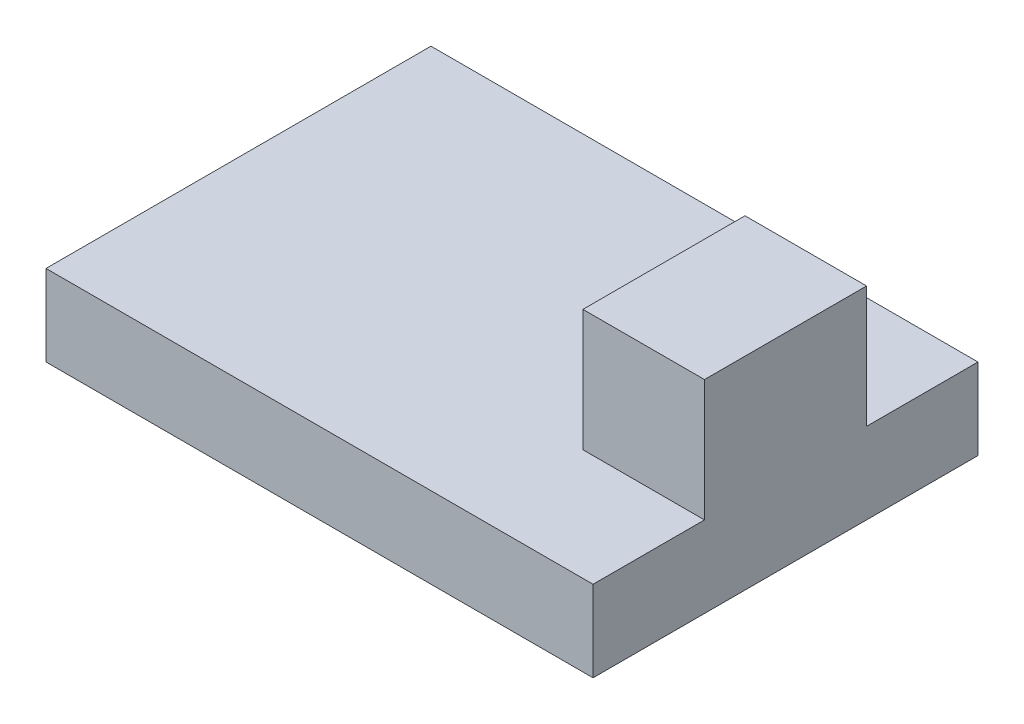
from build123d import *

# Parameters (mm, degrees)
SKETCH1_W           = 27
SKETCH1_H           = 19
BOSS_EXTRUDE1_DEPTH = 4
SKETCH2_W           = 6
SKETCH2_H           = 8
BOSS_EXTRUDE2_DEPTH = 6


with BuildPart() as part:
    # Sketch1 → Boss-Extrude1 (new body)
    with BuildSketch(Plane(origin=(0, 0, 0), x_dir=(1, 0, 0), z_dir=(0, 1, 0))):
        Rectangle(SKETCH1_W, SKETCH1_H)
    extrude(amount=BOSS_EXTRUDE1_DEPTH)

    # Sketch2 → Boss-Extrude2 (add)
    with BuildSketch(Plane(origin=(0, 4, 0), x_dir=(1, 0, 0), z_dir=(0, 1, 0))):
        with Locations((10.5, 0)):
            Rectangle(SKETCH2_W, SKETCH2_H)
    extrude(amount=BOSS_EXTRUDE2_DEPTH)


solid = part.part
